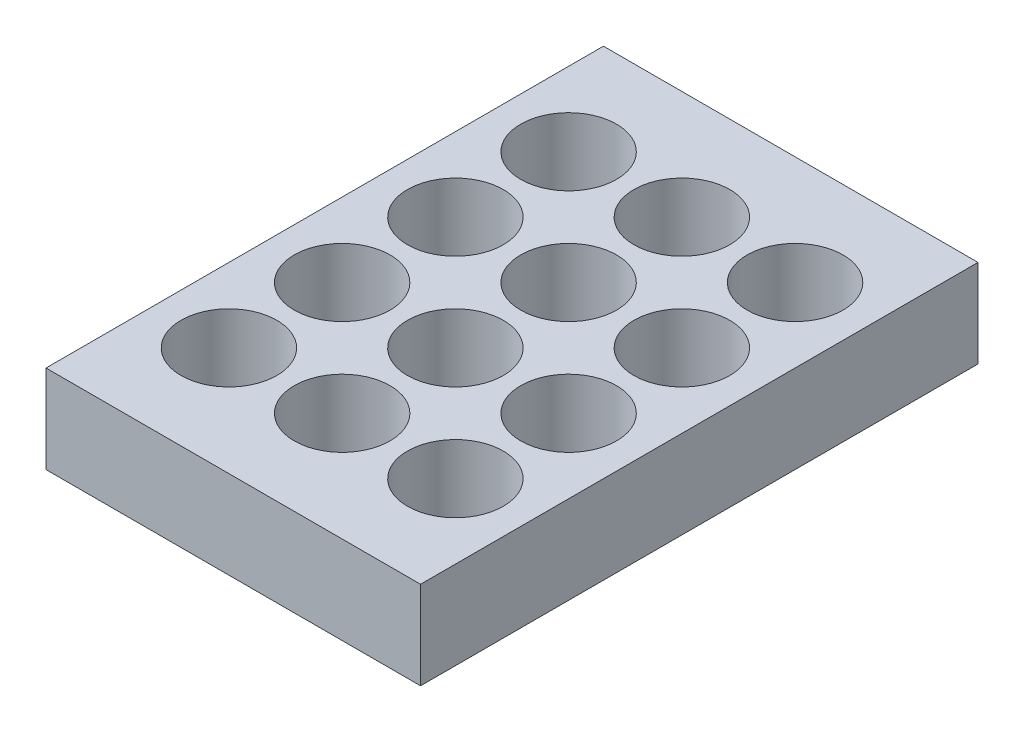
from build123d import *

# Parameters (mm, degrees)
SKETCH1_W            = 86
SKETCH1_H            = 128
BOSS_EXTRUDE1_DEPTH  = 20.2
SKETCH2_R            = 11
CUT_EXTRUDE1_DEPTH   = 17.7
LPATTERN3_COUNT      = 4
LPATTERN3_PITCH      = 26
LPATTERN3_COUNT_DIR2 = 3
LPATTERN3_PITCH_DIR2 = 26


with BuildPart() as part:
    # Sketch1 → Boss-Extrude1 (new body)
    with BuildSketch(Plane(origin=(0, 0, 0), x_dir=(1, 0, 0), z_dir=(0, 1, 0))):
        with Locations((43, 64)):
            Rectangle(SKETCH1_W, SKETCH1_H)
    extrude(amount=BOSS_EXTRUDE1_DEPTH)

    # Sketch2 → Cut-Extrude1 (cut)
    with BuildSketch(Plane(origin=(0, 20.2, 0), x_dir=(1, 0, 0), z_dir=(0, 1, 0))):
        with Locations((17, 25)):
            Circle(SKETCH2_R)
    cut_extrude1 = extrude(amount=-CUT_EXTRUDE1_DEPTH, mode=Mode.SUBTRACT)

    # LPattern3: Cut-Extrude1 4 × 3
    with Locations(*[(j * LPATTERN3_PITCH_DIR2, 0, -i * LPATTERN3_PITCH) for i in range(LPATTERN3_COUNT) for j in range(LPATTERN3_COUNT_DIR2) if (i, j) != (0, 0)]):
        add(cut_extrude1, mode=Mode.SUBTRACT)


solid = part.part
